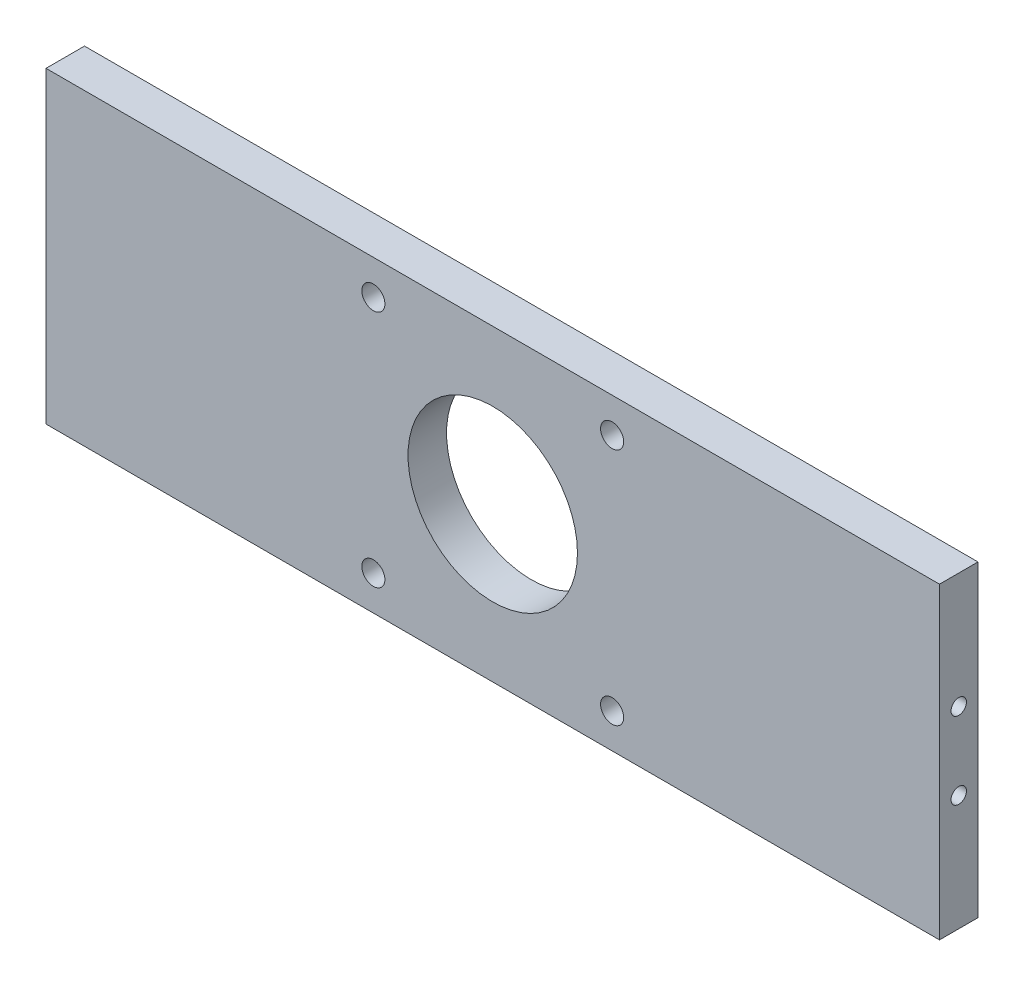
from build123d import *

# Parameters (mm, degrees)
SKETCH1_W           = 116
SKETCH1_H           = 40
SKETCH1_R           = 11
SKETCH1_R_2         = 1.5
BOSS_EXTRUDE2_DEPTH = 5
SKETCH4_R           = 1
CUT_EXTRUDE1_DEPTH  = 10
SKETCH6_R           = 1
CUT_EXTRUDE2_DEPTH  = 5


with BuildPart() as part:
    # Sketch1 → Boss-Extrude2 (new body)
    with BuildSketch(Plane.XY):
        Rectangle(SKETCH1_W, SKETCH1_H)
        Circle(SKETCH1_R, mode=Mode.SUBTRACT)
        with Locations((-15.5, 15.5)):
            Circle(SKETCH1_R_2, mode=Mode.SUBTRACT)
        with Locations((-15.5, -15.5)):
            Circle(SKETCH1_R_2, mode=Mode.SUBTRACT)
        with Locations((15.5, -15.5)):
            Circle(SKETCH1_R_2, mode=Mode.SUBTRACT)
        with Locations((15.5, 15.5)):
            Circle(SKETCH1_R_2, mode=Mode.SUBTRACT)
    extrude(amount=BOSS_EXTRUDE2_DEPTH)

    # Sketch4 → Cut-Extrude1 (cut)
    with BuildSketch(Plane(origin=(58, 0, 0), x_dir=(0, 0, -1), z_dir=(1, 0, 0))):
        with Locations((-2.5, -5)):
            Circle(SKETCH4_R)
        with Locations((-2.5, 5)):
            Circle(SKETCH4_R)
    extrude(amount=-CUT_EXTRUDE1_DEPTH, mode=Mode.SUBTRACT)

    # Sketch6 → Cut-Extrude2 (cut)
    with BuildSketch(Plane.ZY.offset(58)):
        with Locations((2.5, 5)):
            Circle(SKETCH6_R)
        with Locations((2.5, -5)):
            Circle(SKETCH6_R)
    extrude(amount=-CUT_EXTRUDE2_DEPTH, mode=Mode.SUBTRACT)


solid = part.part
